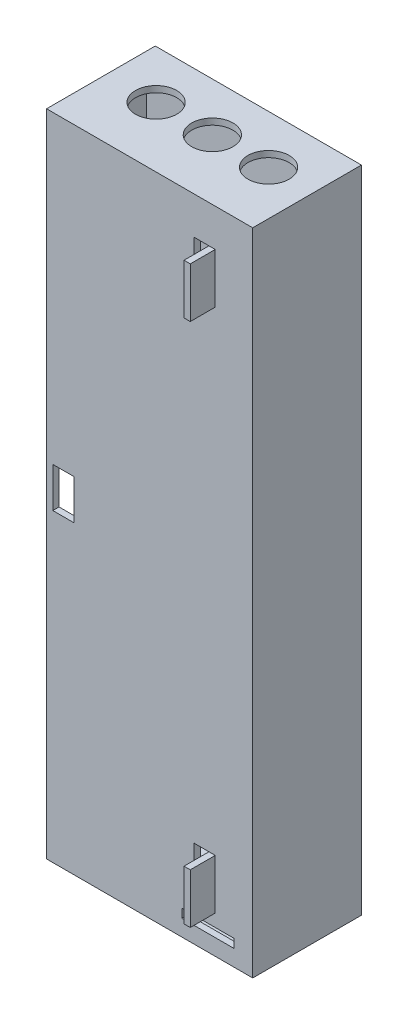
from build123d import *

# Parameters (mm, degrees)
SKETCH1_W           = 260
SKETCH1_H           = 85
BOSS_EXTRUDE1_DEPTH = 2.5
SKETCH2_W           = 85
SKETCH2_H           = 260
SKETCH2_W_2         = 80
SKETCH2_H_2         = 255
BOSS_EXTRUDE2_DEPTH = 35
SKETCH3_W           = 85
SKETCH3_H           = 260
BOSS_EXTRUDE3_DEPTH = 6
SKETCH4_W           = 260
SKETCH4_H           = 43.5
CUT_EXTRUDE1_DEPTH  = 2.5
CUT_EXTRUDE2_REACH  = 45.5
SKETCH5_W           = 8.5
SKETCH5_H           = 16
SKETCH14_R          = 8.25
CUT_EXTRUDE8_DEPTH  = 2.5
SKETCH22_R          = 8.25
CUT_EXTRUDE9_DEPTH  = 10
CUT_EXTRUDE11_REACH = 45.5
SKETCH25_W          = 20.88469263
SKETCH25_H          = 3.5
SKETCH27_W          = 30
SKETCH27_H          = 43.5
BOSS_EXTRUDE4_DEPTH = 2.5
SKETCH29_W          = 2.5
SKETCH29_H          = 20
BOSS_EXTRUDE5_DEPTH = 10
SKETCH30_W          = 6
SKETCH30_H          = 20
CUT_EXTRUDE12_DEPTH = 5


with BuildPart() as part:
    # Sketch1 → Boss-Extrude1 (new body)
    with BuildSketch(Plane(origin=(0, 0, 0), x_dir=(0, 1, 0), z_dir=(0, 0, 1))):
        Rectangle(SKETCH1_W, SKETCH1_H)
    extrude(amount=BOSS_EXTRUDE1_DEPTH)

    # Sketch2 → Boss-Extrude2 (add)
    with BuildSketch(Plane(origin=(0, 0, 0), x_dir=(1, 0, 0), z_dir=(0, 0, -1))):
        Rectangle(SKETCH2_W, SKETCH2_H)
        Rectangle(SKETCH2_W_2, SKETCH2_H_2, mode=Mode.SUBTRACT)
    extrude(amount=BOSS_EXTRUDE2_DEPTH)

    # Sketch3 → Boss-Extrude3 (add)
    with BuildSketch(Plane(origin=(0, 0, -35), x_dir=(1, 0, 0), z_dir=(0, 0, -1))):
        Rectangle(SKETCH3_W, SKETCH3_H)
    extrude(amount=BOSS_EXTRUDE3_DEPTH)

    # Sketch4 → Cut-Extrude1 (cut)
    with BuildSketch(Plane(origin=(-42.5, 0, 0), x_dir=(0, -1, 0), z_dir=(-1, 0, 0))):
        with Locations((0, -19.25)):
            Rectangle(SKETCH4_W, SKETCH4_H)
    extrude(amount=-CUT_EXTRUDE1_DEPTH, mode=Mode.SUBTRACT)

    # Sketch5 → Cut-Extrude2 (cut, up to next)
    with BuildSketch(Plane.XY.offset(2.5), mode=Mode.PRIVATE) as cut_extrude2_sk1:
        with Locations((-33.25, 0)):
            Rectangle(SKETCH5_W, SKETCH5_H)
    cut_extrude2_tool1 = extrude(cut_extrude2_sk1.sketch, amount=-CUT_EXTRUDE2_REACH, mode=Mode.PRIVATE) & part.part
    add(cut_extrude2_tool1.solids().sort_by_distance((-33.25, 0, 2.5))[0], mode=Mode.SUBTRACT)

    # Sketch14 → Cut-Extrude8 (cut)
    with BuildSketch(Plane.XZ.offset(130)):
        with Locations((-20.95492543, -21.33509917)):
            Circle(SKETCH14_R)
    extrude(amount=-CUT_EXTRUDE8_DEPTH, mode=Mode.SUBTRACT)

    # Sketch22 → Cut-Extrude9 (cut)
    with BuildSketch(Plane(origin=(0, 130, 0), x_dir=(-1, 0, 0), z_dir=(0, 1, 0))):
        with Locations((-24.702923979, -21.634364917)):
            Circle(SKETCH22_R)
        with Locations((-2.202923979, -21.634364917)):
            Circle(SKETCH22_R)
        with Locations((20.297076021, -21.634364917)):
            Circle(SKETCH22_R)
    extrude(amount=-CUT_EXTRUDE9_DEPTH, mode=Mode.SUBTRACT)

    # Sketch25 → Cut-Extrude11 (cut, up to next)
    with BuildSketch(Plane.XY.offset(2.5), mode=Mode.PRIVATE) as cut_extrude11_sk1:
        with Locations((24.557653685, -121.75)):
            Rectangle(SKETCH25_W, SKETCH25_H)
    cut_extrude11_tool1 = extrude(cut_extrude11_sk1.sketch, amount=-CUT_EXTRUDE11_REACH, mode=Mode.PRIVATE) & part.part
    add(cut_extrude11_tool1.solids().sort_by_distance((24.557654, -121.75, 2.5))[0], mode=Mode.SUBTRACT)

    # Sketch27 → Boss-Extrude4 (add)
    with BuildSketch(Plane(origin=(-40, 0, 0), x_dir=(0, -1, 0), z_dir=(-1, 0, 0))):
        with Locations((-115, -19.25)):
            Rectangle(SKETCH27_W, SKETCH27_H)
        with Locations((115, -19.25)):
            Rectangle(SKETCH27_W, SKETCH27_H)
    extrude(amount=-BOSS_EXTRUDE4_DEPTH)

    # Sketch29 → Boss-Extrude5 (add)
    with BuildSketch(Plane.XY.offset(2.5)):
        with Locations((26.25, -105)):
            Rectangle(SKETCH29_W, SKETCH29_H)
    boss_extrude5 = extrude(amount=BOSS_EXTRUDE5_DEPTH)

    # Sketch30 → Cut-Extrude12 (cut)
    with BuildSketch(Plane.XY.offset(2.5)):
        with Locations((22, -105)):
            Rectangle(SKETCH30_W, SKETCH30_H)
    cut_extrude12 = extrude(amount=-CUT_EXTRUDE12_DEPTH, mode=Mode.SUBTRACT)

    # Mirror2: Boss-Extrude5, Cut-Extrude12 across plane
    add(boss_extrude5.mirror(Plane.ZX))
    add(cut_extrude12.mirror(Plane.ZX), mode=Mode.SUBTRACT)


solid = part.part
